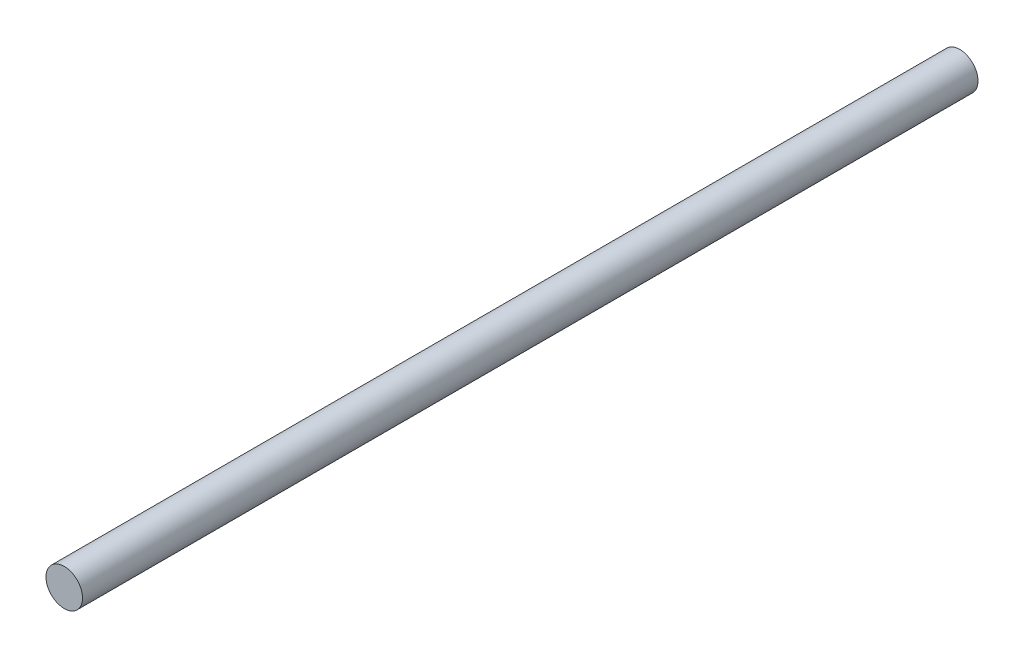
from build123d import *

# Parameters (mm, degrees)
SKETCH1_R           = 4
BOSS_EXTRUDE1_DEPTH = 196


with BuildPart() as part:
    # Sketch1 → Boss-Extrude1 (new body)
    with BuildSketch(Plane.XY):
        Circle(SKETCH1_R)
    extrude(amount=BOSS_EXTRUDE1_DEPTH)


solid = part.part
